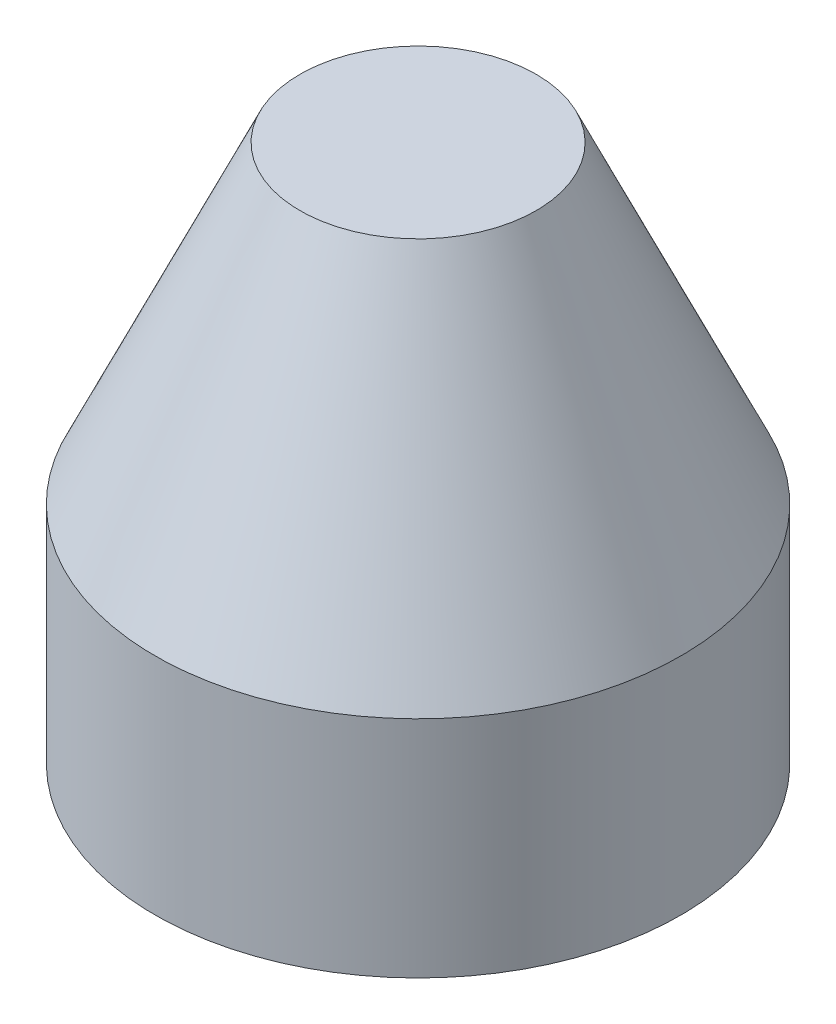
from build123d import *

# Parameters (mm, degrees)
F_12_0MM_DOWEL_HOLE1_D     = 12
F_12_0MM_DOWEL_HOLE1_DEPTH = 20
F_12_0MM_DOWEL_HOLE1_TIP   = 3.605163714


with BuildPart() as part:
    # Sketch1 → Revolve1 (revolve)
    with BuildSketch(Plane.XY):
        Polygon((0, 0), (0, 45.5188), (10, 45.5188), (22.25, 19), (22.25, 0), align=None)
    revolve(axis=Axis((0, 0, 0), (0, 1, 0)))

    # Ø12.0mm Dowel Hole1
    with Locations(Plane(origin=(0, 0, 0), x_dir=(-1, 0, 0), z_dir=(0, -1, 0))):
        with Locations((0, 0)):
            Hole(F_12_0MM_DOWEL_HOLE1_D / 2, depth=F_12_0MM_DOWEL_HOLE1_DEPTH)
            with Locations((0, 0, -(F_12_0MM_DOWEL_HOLE1_DEPTH + F_12_0MM_DOWEL_HOLE1_TIP / 2))):  # 118° drill point
                Cone(0, F_12_0MM_DOWEL_HOLE1_D / 2, F_12_0MM_DOWEL_HOLE1_TIP, mode=Mode.SUBTRACT)


solid = part.part
